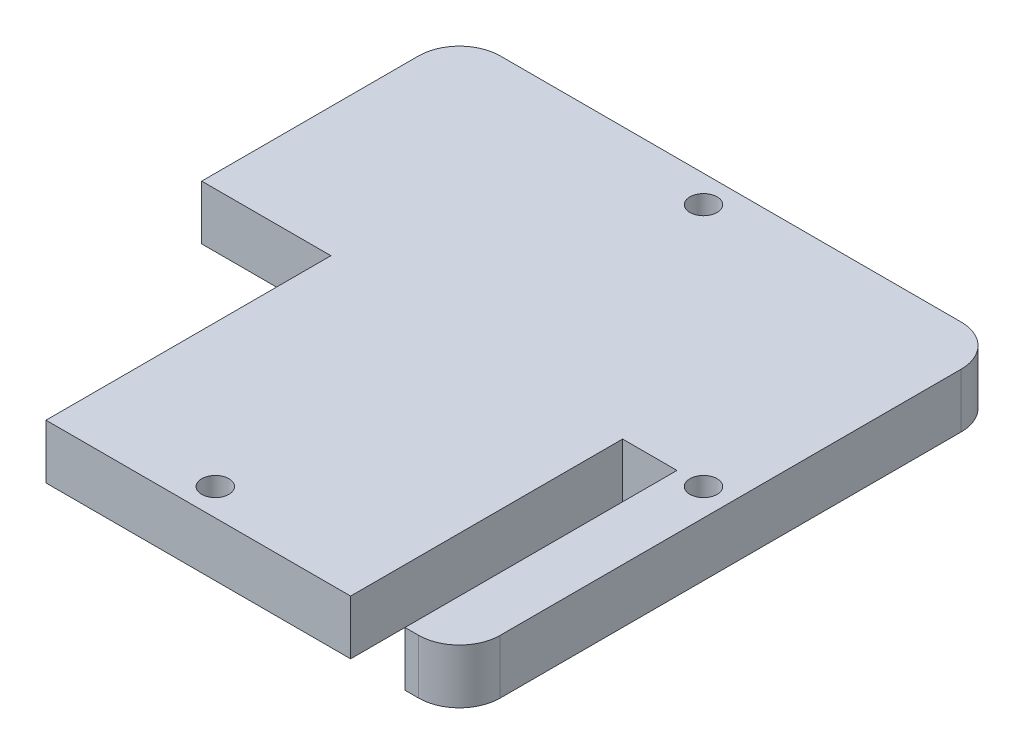
from build123d import *

# Parameters (mm, degrees)
CROQUIS1_W                 = 39.9
CROQUIS1_H                 = 39.9
SALIENTE_EXTRUIR1_DEPTH    = 2
CROQUIS7_W                 = 4
CROQUIS7_H                 = 20
CORTAR_EXTRUIR3_DEPTH      = 3
CORTAR_EXTRUIR3_DEPTH_BACK = 3
CROQUIS9_R                 = 1
CORTAR_EXTRUIR4_DEPTH      = 1
CORTAR_EXTRUIR4_DEPTH_BACK = 5
REDONDEO8_R                = 3
CROQUIS10_W                = 9.5
CROQUIS10_H                = 20.95
CORTAR_EXTRUIR5_DEPTH      = 1
CORTAR_EXTRUIR5_DEPTH_BACK = 5


with BuildPart() as part:
    # Croquis1 → Saliente-Extruir1 (new body, symmetric)
    with BuildSketch(Plane(origin=(0, 0, 0), x_dir=(1, 0, 0), z_dir=(0, 1, 0))):
        Rectangle(CROQUIS1_W, CROQUIS1_H)
    extrude(amount=SALIENTE_EXTRUIR1_DEPTH, both=True)

    # Croquis7 → Cortar-Extruir3 (cut, two sides)
    with BuildSketch(Plane(origin=(0, 0, 0), x_dir=(1, 0, 0), z_dir=(0, 1, 0))) as cortar_extruir3_sk:
        with Locations((13.95, -9.95)):
            Rectangle(CROQUIS7_W, CROQUIS7_H)
        with Locations((-13.95, -9.95)):
            Rectangle(CROQUIS7_W, CROQUIS7_H)
    extrude(amount=CORTAR_EXTRUIR3_DEPTH, mode=Mode.SUBTRACT)
    extrude(cortar_extruir3_sk.sketch, amount=-CORTAR_EXTRUIR3_DEPTH_BACK, mode=Mode.SUBTRACT)

    # Croquis9 → Cortar-Extruir4 (cut, two sides)
    with BuildSketch(Plane.XZ.offset(2)) as cortar_extruir4_sk:
        with Locations((0, 17.95)):
            Circle(CROQUIS9_R)
        with Locations((-17.95, 0)):
            Circle(CROQUIS9_R)
        with Locations((0, -17.95)):
            Circle(CROQUIS9_R)
        with Locations((17.95, 0)):
            Circle(CROQUIS9_R)
    extrude(amount=CORTAR_EXTRUIR4_DEPTH, mode=Mode.SUBTRACT)
    extrude(cortar_extruir4_sk.sketch, amount=-CORTAR_EXTRUIR4_DEPTH_BACK, mode=Mode.SUBTRACT)

    # Redondeo8
    redondeo8_edges = [part.edges().sort_by_distance(p)[0] for p in [
        (19.95, 0, 19.95),
        (-19.95, 0, 19.95),
        (-19.95, 0, -19.95),
        (19.95, 0, -19.95),
    ]]
    fillet(redondeo8_edges, radius=REDONDEO8_R)

    # Croquis10 → Cortar-Extruir5 (cut, two sides)
    with BuildSketch(Plane(origin=(0, 2, 0), x_dir=(1, 0, 0), z_dir=(0, 1, 0))) as cortar_extruir5_sk:
        with Locations((-15.2, -9.475)):
            Rectangle(CROQUIS10_W, CROQUIS10_H)
    extrude(amount=CORTAR_EXTRUIR5_DEPTH, mode=Mode.SUBTRACT)
    extrude(cortar_extruir5_sk.sketch, amount=-CORTAR_EXTRUIR5_DEPTH_BACK, mode=Mode.SUBTRACT)


solid = part.part
